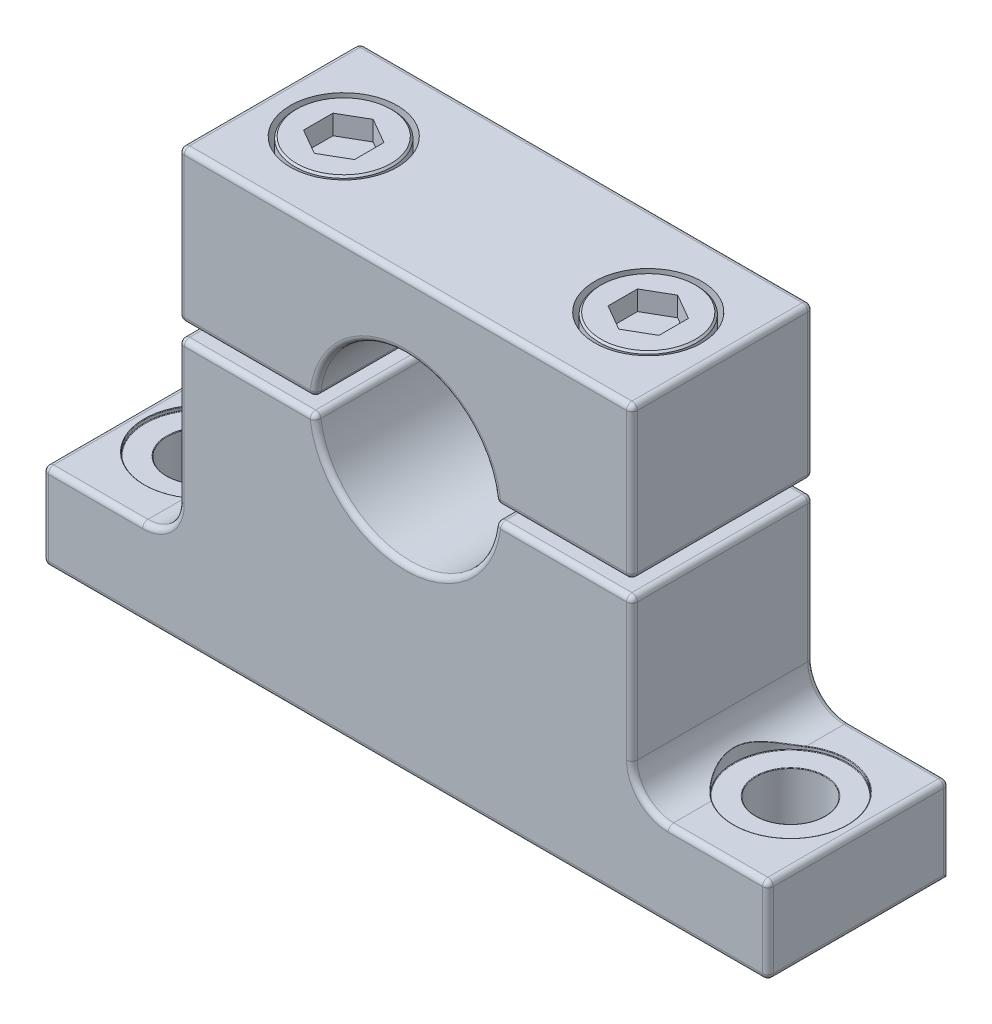
from build123d import *

# Parameters (mm, degrees)
BOSS_EXTRUDE1_DEPTH   = 12.7
BOSS_EXTRUDE1_2_DEPTH = 12.7
SKETCH4_R             = 2.413
CUT_EXTRUDE1_DEPTH    = 31.1625
SKETCH8_R             = 3.9751
CUT_EXTRUDE3_DEPTH    = 12.7635
SKETCH10_R            = 2.3368
CUT_EXTRUDE4_DEPTH    = 31.1625
SKETCH12_R            = 3.7465
CUT_EXTRUDE5_DEPTH    = 4.5466
CHAMFER1_SIZE         = 0.127
CUT_EXTRUDE6_DEPTH    = 1.374648
FILLET1_R             = 0.381
FILLET2_R             = 0.381
FILLET3_R             = 0.0381


with BuildPart() as part:
    # Sketch3 → Boss-Extrude1 (new body)
    with BuildSketch(Plane.XY):
        with BuildLine():
            Line((-15.875, 30.1625), (15.875, 30.1625))
            Line((15.875, 30.1625), (15.875, 19.558))
            Line((15.875, 19.558), (6.329647384, 19.558))
            ThreePointArc((6.329647384, 19.558), (0, 25.4), (-6.329647384, 19.558))
            Line((-6.329647384, 19.558), (-15.875, 19.558))
            Line((-15.875, 19.558), (-15.875, 30.1625))
        make_face()
    extrude(amount=-BOSS_EXTRUDE1_DEPTH)


with BuildPart() as body_2:
    # Sketch3 → Boss-Extrude1 2 (new body)
    with BuildSketch(Plane.XY):
        with BuildLine():
            Line((-15.875, 18.542), (-15.875, 8.5725))
            ThreePointArc((-15.875, 8.5725), (-16.618948776, 6.776448776), (-18.415, 6.0325))
            Line((-18.415, 6.0325), (-25.4, 6.0325))
            Line((-25.4, 6.0325), (-25.4, 0))
            Line((-25.4, 0), (25.4, 0))
            Line((25.4, 0), (25.4, 6.0325))
            Line((25.4, 6.0325), (18.415, 6.0325))
            ThreePointArc((18.415, 6.0325), (16.618948776, 6.776448776), (15.875, 8.5725))
            Line((15.875, 8.5725), (15.875, 18.542))
            Line((15.875, 18.542), (6.329647384, 18.542))
            ThreePointArc((6.329647384, 18.542), (0, 12.7), (-6.329647384, 18.542))
            Line((-6.329647384, 18.542), (-15.875, 18.542))
        make_face()
    extrude(amount=-BOSS_EXTRUDE1_2_DEPTH)

    # Sketch4 → Cut-Extrude1 (cut, through all)
    with BuildSketch(Plane.XZ):
        with Locations((-20.6375, -6.35)):
            Circle(SKETCH4_R)
        with Locations((20.6375, -6.35)):
            Circle(SKETCH4_R)
    extrude(amount=-CUT_EXTRUDE1_DEPTH, mode=Mode.SUBTRACT)

    # Sketch8 → Cut-Extrude3 (cut)
    with BuildSketch(Plane(origin=(0, 18.542, 0), x_dir=(1, 0, 0), z_dir=(0, 1, 0))):
        with Locations((-20.6375, 6.35)):
            Circle(SKETCH8_R)
        with Locations((20.6375, 6.35)):
            Circle(SKETCH8_R)
    extrude(amount=-CUT_EXTRUDE3_DEPTH, mode=Mode.SUBTRACT)


with BuildPart() as cut_extrude4_tool:
    # Sketch10 → Cut-Extrude4 (new body, through all)
    with BuildSketch(Plane(origin=(0, 30.1625, 0), x_dir=(1, 0, 0), z_dir=(0, 1, 0))):
        with Locations((10.668, 6.35)):
            Circle(SKETCH10_R)
        with Locations((-10.668, 6.35)):
            Circle(SKETCH10_R)
    extrude(amount=-CUT_EXTRUDE4_DEPTH)


with BuildPart() as part_1:
    add(part.part)

    # Cut-Extrude4: cut by cut_extrude4_tool
    add(cut_extrude4_tool.part, mode=Mode.SUBTRACT)

    # Sketch12 → Cut-Extrude5 (cut)
    with BuildSketch(Plane(origin=(0, 30.1625, 0), x_dir=(1, 0, 0), z_dir=(0, 1, 0))):
        with Locations((10.668, 6.35)):
            Circle(SKETCH12_R)
        with Locations((-10.668, 6.35)):
            Circle(SKETCH12_R)
    extrude(amount=-CUT_EXTRUDE5_DEPTH, mode=Mode.SUBTRACT)

    # Fillet1
    fillet1_edges = [part_1.edges().sort_by_distance(p)[0] for p in [
        (0, 25.4, -12.7),
        (-15.875, 30.1625, -6.35),
        (15.875, 30.1625, -6.35),
        (15.875, 19.558, -6.35),
        (6.329647384, 19.558, -6.35),
        (-6.329647384, 19.558, -6.35),
        (-15.875, 19.558, -6.35),
        (11.102323692, 19.558, -12.7),
        (15.875, 24.86025, -12.7),
        (0, 30.1625, -12.7),
        (-15.875, 24.86025, -12.7),
        (0, 30.1625, 0),
        (15.875, 24.86025, 0),
        (11.102323692, 19.558, 0),
        (-11.102323692, 19.558, -12.7),
        (0, 25.4, 0),
        (-11.102323692, 19.558, 0),
        (-15.875, 24.86025, 0),
    ]]
    fillet(fillet1_edges, radius=FILLET1_R)


with BuildPart() as body_2_1:
    add(body_2.part)

    # Cut-Extrude4: cut by cut_extrude4_tool
    add(cut_extrude4_tool.part, mode=Mode.SUBTRACT)

    # Fillet2
    fillet2_edges = [body_2_1.edges().sort_by_distance(p)[0] for p in [
        (-16.618948776, 6.776448776, -12.7),
        (0, 12.7, 0),
        (11.102323692, 18.542, 0),
        (15.875, 13.55725, 0),
        (16.618948776, 6.776448776, 0),
        (21.9075, 6.0325, 0),
        (25.4, 3.01625, 0),
        (-21.9075, 6.0325, -12.7),
        (0, 0, 0),
        (-25.4, 3.01625, 0),
        (-21.9075, 6.0325, 0),
        (-16.618948776, 6.776448776, 0),
        (-15.875, 13.55725, 0),
        (-11.102323692, 18.542, 0),
        (-25.4, 3.01625, -12.7),
        (-6.329647384, 18.542, -6.35),
        (6.329647384, 18.542, -6.35),
        (15.875, 18.542, -6.35),
        (25.4, 6.0325, -6.35),
        (25.4, 0, -6.35),
        (-25.4, 0, -6.35),
        (-25.4, 6.0325, -6.35),
        (-15.875, 18.542, -6.35),
        (25.4, 3.01625, -12.7),
        (21.9075, 6.0325, -12.7),
        (16.618948776, 6.776448776, -12.7),
        (15.875, 13.55725, -12.7),
        (11.102323692, 18.542, -12.7),
        (0, 12.7, -12.7),
        (-11.102323692, 18.542, -12.7),
        (-15.875, 13.55725, -12.7),
    ]]
    fillet(fillet2_edges, radius=FILLET2_R)

    # Fillet3
    fillet3_edges = [body_2_1.edges().sort_by_distance(p)[0] for p in [
        (-17.127675346, 6.382889222, -4.48384065),
        (-24.6126, 6.0325, -6.35),
        (-24.6126, 5.7785, -6.35),
        (-23.0505, 5.7785, -6.35),
        (22.503881561, 6.0325, -2.840293477),
        (16.6624, 6.734024207, -6.35),
        (18.2245, 5.7785, -6.35),
        (16.6624, 5.7785, -6.35),
    ]]
    fillet(fillet3_edges, radius=FILLET3_R)


with BuildPart() as body_3:
    # Sketch15 → Revolve1 (revolve)
    with BuildSketch(Plane.XY.offset(-6.35)):
        Polygon((-10.668, 12.065), (-10.668, 30.1625), (-14.097, 30.1625), (-14.097, 25.9969), (-12.7508, 25.9969), (-12.7508, 12.065), align=None)
    revolve(axis=Axis((-10.668, 12.065, -6.35), (0, 1, 0)))

    # Chamfer1
    chamfer1_edges = [body_3.edges().sort_by_distance(p)[0] for p in [
        (-7.239, 30.1625, -6.35),
    ]]
    chamfer(chamfer1_edges, length=CHAMFER1_SIZE)

    # Sketch16 → Cut-Extrude6 (cut)
    with BuildSketch(Plane(origin=(0, 30.1625, 0), x_dir=(1, 0, 0), z_dir=(0, 1, 0))):
        Polygon((-10.668, 8.412222993), (-12.4539375, 7.381111496), (-12.4539375, 5.318888504), (-10.668, 4.287777007), (-8.8820625, 5.318888504), (-8.8820625, 7.381111496), align=None)
    extrude(amount=-CUT_EXTRUDE6_DEPTH, mode=Mode.SUBTRACT)


with BuildPart() as body_4:
    # Mirror1: mirrored copy
    add(body_3.part.mirror(Plane(origin=(0, 0, 0), x_dir=(0, 0, 1), z_dir=(1, 0, 0))))


solid = Compound([part_1.part, body_2_1.part, body_3.part, body_4.part])
